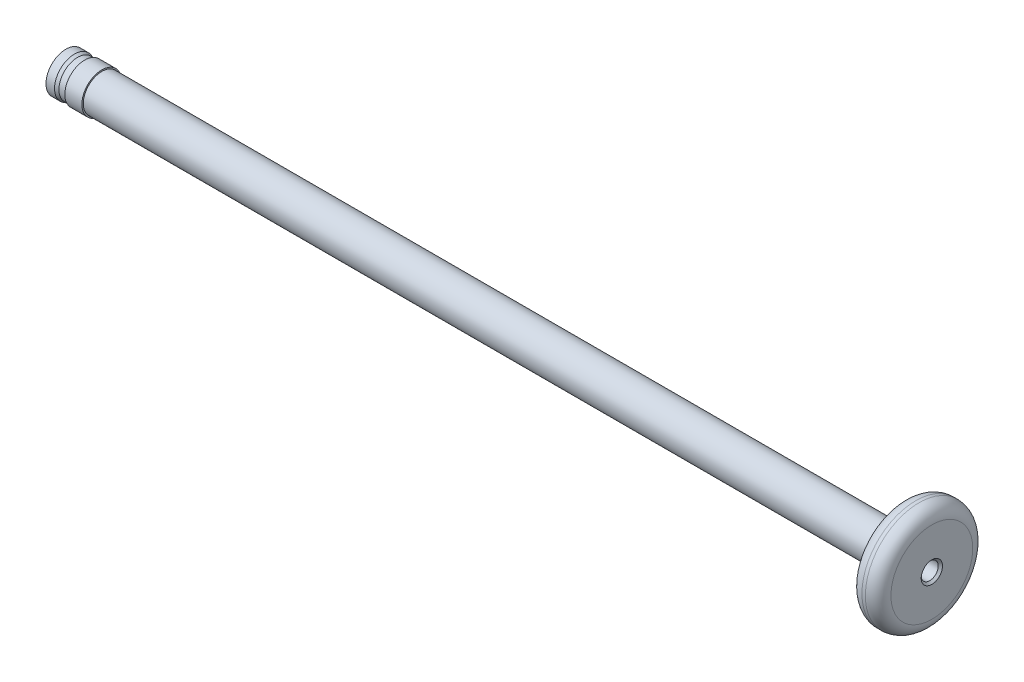
from build123d import *

# Parameters (mm, degrees)
SKETCH2_R          = 1
CUT_EXTRUDE1_DEPTH = 5
FILLET1_R          = 1.5
CHAMFER1_SIZE      = 0.25


with BuildPart() as part:
    # Sketch1 → Revolve1 (revolve)
    with BuildSketch(Plane.XY):
        Polygon((-49.42, 2.185), (-48.59, 2.185), (-48.5768767, 2.335), (-46.5768767, 2.335), (-46.563753401, 2.185), (47.4, 2.185), (47.4, 6.3), (50.8, 6.3), (50.8, 0), (-50.8, 0), (-50.8, 2.185), (-50.7868767, 2.335), (-49.7868767, 2.335), align=None)
    revolve(axis=Axis((-50.8, 0, 0), (1, 0, 0)))

    # Sketch2 → Cut-Extrude1 (cut)
    with BuildSketch(Plane(origin=(50.8, 0, 0), x_dir=(0, 0, -1), z_dir=(1, 0, 0))):
        Circle(SKETCH2_R)
    extrude(amount=-CUT_EXTRUDE1_DEPTH, mode=Mode.SUBTRACT)

    # Fillet1
    fillet1_edges = [part.edges().sort_by_distance(p)[0] for p in [
        (47.4, -6.3, 0),
        (50.8, -6.3, 0),
    ]]
    fillet(fillet1_edges, radius=FILLET1_R)

    # Chamfer1
    chamfer1_edges = [part.edges().sort_by_distance(p)[0] for p in [
        (50.8, 0, 1),
    ]]
    chamfer(chamfer1_edges, length=CHAMFER1_SIZE)


solid = part.part
